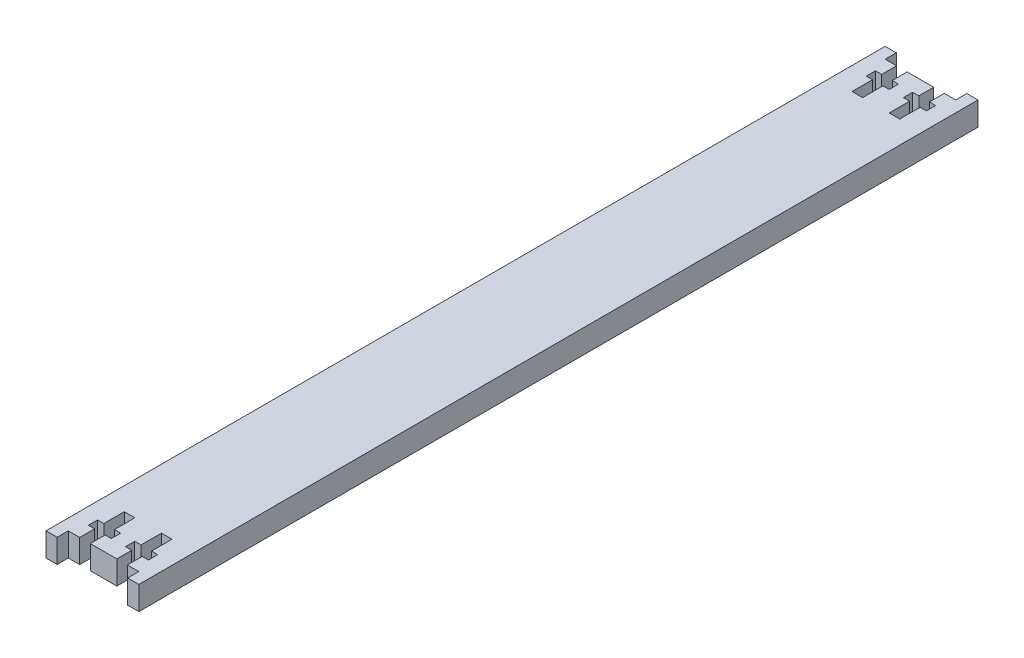
from build123d import *

# Parameters (mm, degrees)
BOSS_EXTRUDE1_DEPTH = 6.35


with BuildPart() as part:
    # Sketch1 → Boss-Extrude1 (new body)
    with BuildSketch(Plane(origin=(0, 0, 0), x_dir=(1, 0, 0), z_dir=(0, 1, 0))):
        Polygon((8.9224, 220), (8.9224, 216), (10.6, 216), (10.6, 213.5), (8.9224, 213.5), (8.9224, 208), (6.0776, 208), (6.0776, 213.5), (4.4, 213.5), (4.4, 216), (6.0776, 216), (6.0776, 220), (3, 220), (3, 223), (0, 223), (0, 220), (0, 0), (0, -3), (3, -3), (3, 0), (6.0776, 0), (6.0776, 4), (4.4, 4), (4.4, 6.5), (6.0776, 6.5), (6.0776, 12), (8.9224, 12), (8.9224, 6.5), (10.6, 6.5), (10.6, 4), (8.9224, 4), (8.9224, 0), (16.0776, 0), (16.0776, 4), (14.4, 4), (14.4, 6.5), (16.0776, 6.5), (16.0776, 12), (18.9224, 12), (18.9224, 6.5), (20.6, 6.5), (20.6, 4), (18.9224, 4), (18.9224, 0), (22, 0), (22, -3), (25, -3), (25, 0), (25, 220), (25, 223), (22, 223), (22, 220), (18.9224, 220), (18.9224, 216), (20.6, 216), (20.6, 213.5), (18.9224, 213.5), (18.9224, 208), (16.0776, 208), (16.0776, 213.5), (14.4, 213.5), (14.4, 216), (16.0776, 216), (16.0776, 220), align=None)
    extrude(amount=BOSS_EXTRUDE1_DEPTH)


solid = part.part
